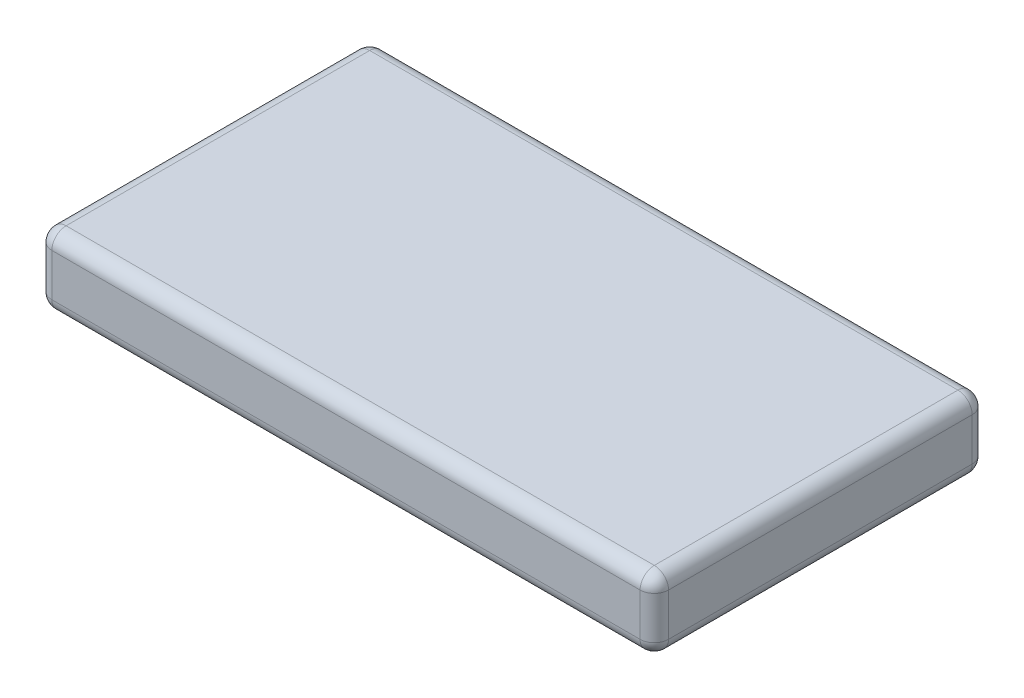
from build123d import *

# Parameters (mm, degrees)
SKETCH1_W           = 130
SKETCH1_H           = 70
BOSS_EXTRUDE1_DEPTH = 15
FILLET1_R           = 3


with BuildPart() as part:
    # Sketch1 → Boss-Extrude1 (new body)
    with BuildSketch(Plane(origin=(0, 0, 0), x_dir=(1, 0, 0), z_dir=(0, 1, 0))):
        Rectangle(SKETCH1_W, SKETCH1_H)
    extrude(amount=BOSS_EXTRUDE1_DEPTH)

    # Fillet1
    fillet1_edges = [part.edges().sort_by_distance(p)[0] for p in [
        (-65, 15, 0),
        (0, 15, 35),
        (65, 15, 0),
        (0, 0, 35),
        (-65, 0, 0),
        (0, 0, -35),
        (65, 0, 0),
        (0, 15, -35),
        (65, 7.5, 35),
        (-65, 7.5, 35),
        (-65, 7.5, -35),
        (65, 7.5, -35),
    ]]
    fillet(fillet1_edges, radius=FILLET1_R)


solid = part.part
